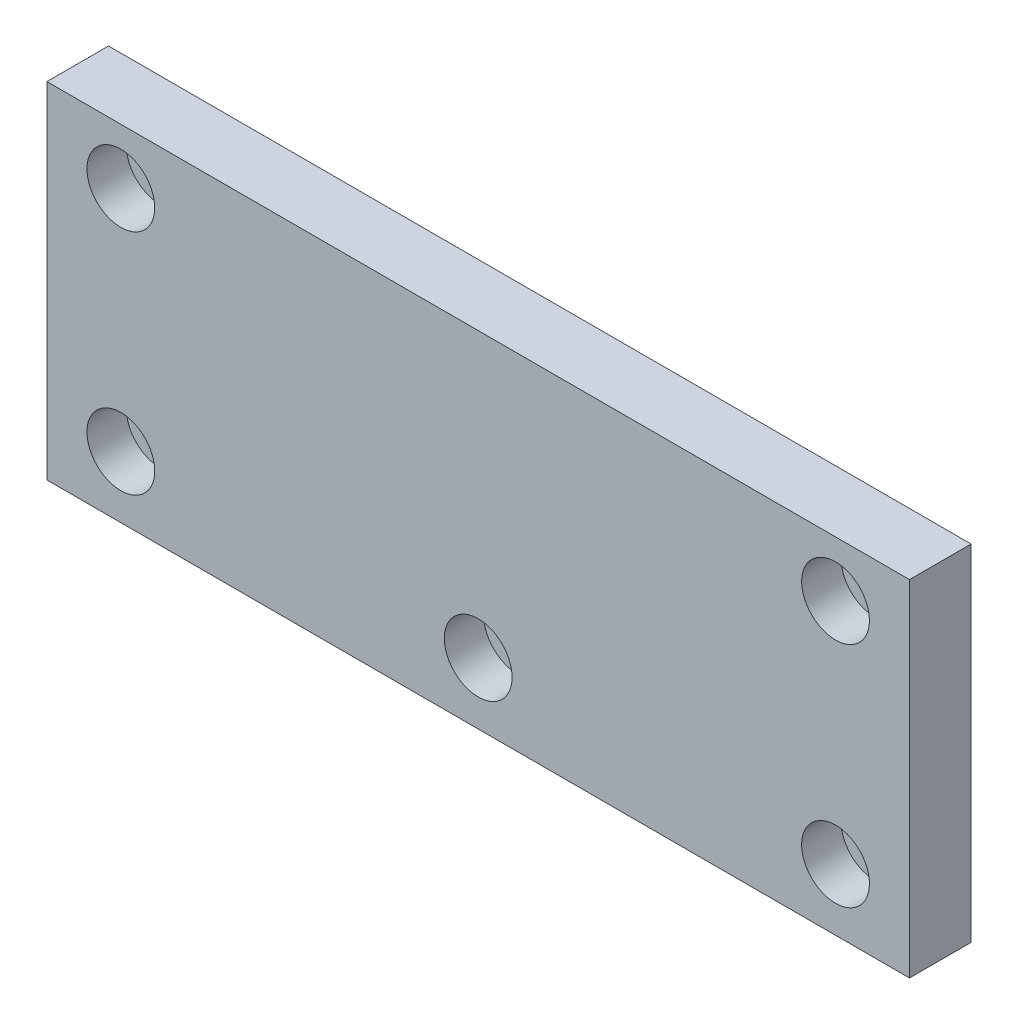
from build123d import *

# Parameters (mm, degrees)
SKETCH1_W                                           = 140
SKETCH1_H                                           = 56
EXTRUDE1_DEPTH                                      = 10
CBORE_FOR_M6_HEX_SOCKET_HEAD_CAP_SCREW1_D           = 6.6
CBORE_FOR_M6_HEX_SOCKET_HEAD_CAP_SCREW1_CBORE_D     = 11
CBORE_FOR_M6_HEX_SOCKET_HEAD_CAP_SCREW1_CBORE_DEPTH = 6.4


with BuildPart() as part:
    # Sketch1 → Extrude1 (new body)
    with BuildSketch(Plane.XY):
        Rectangle(SKETCH1_W, SKETCH1_H)
    extrude(amount=EXTRUDE1_DEPTH)

    # CBORE for M6 Hex Socket Head Cap Screw1 (through all)
    with Locations(Plane.XY.offset(10)):
        with Locations((58, -18), (58, 19), (0, -18), (-58, -18), (-58, 19)):
            CounterBoreHole(CBORE_FOR_M6_HEX_SOCKET_HEAD_CAP_SCREW1_D / 2, CBORE_FOR_M6_HEX_SOCKET_HEAD_CAP_SCREW1_CBORE_D / 2, CBORE_FOR_M6_HEX_SOCKET_HEAD_CAP_SCREW1_CBORE_DEPTH)


solid = part.part
